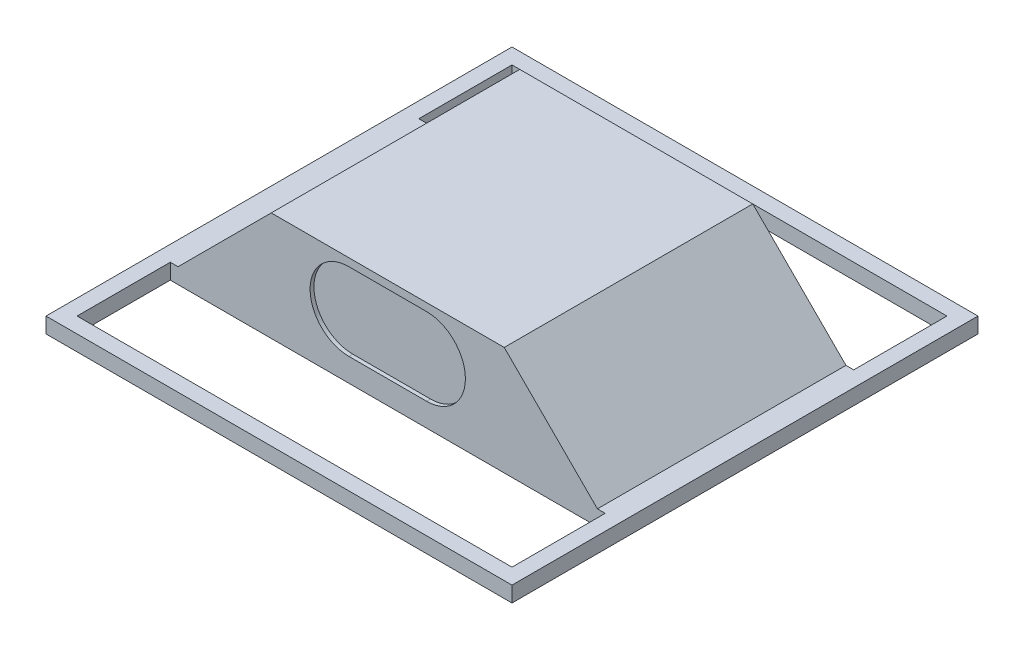
from build123d import *

# Parameters (mm, degrees)
SKETCH_1_W          = 600
SKETCH_1_H          = 600
SKETCH_1_W_2        = 560
SKETCH_1_H_2        = 120
EXTRUDE_1_DEPTH     = 20
EXTRUDE_2_DEPTH     = 320
CUT_EXTRUDE_1_DEPTH = 5
CUT_EXTRUDE_START   = -320
CUT_EXTRUDE_3_DEPTH = 5


with BuildPart() as part:
    # 草图1 → 凸台-拉伸1 (new body)
    with BuildSketch(Plane(origin=(0, 0, 0), x_dir=(1, 0, 0), z_dir=(0, 1, 0))):
        Rectangle(SKETCH_1_W, SKETCH_1_H)
        with Locations((0, 220)):
            Rectangle(SKETCH_1_W_2, SKETCH_1_H_2, mode=Mode.SUBTRACT)
        with Locations((0, -220)):
            Rectangle(SKETCH_1_W_2, SKETCH_1_H_2, mode=Mode.SUBTRACT)
    extrude(amount=EXTRUDE_1_DEPTH)

    # 草图2 → 凸台-拉伸2 (add)
    with BuildSketch(Plane.XY.offset(160)):
        Polygon((-270, 20), (-270, 0), (270, 0), (270, 20), (150, 140), (-150, 140), align=None)
    extrude(amount=-EXTRUDE_2_DEPTH)

    # 草图3 → 切除-拉伸1 (cut)
    with BuildSketch(Plane.XY.offset(160)):
        with BuildLine():
            Line((50, 130), (-50, 130))
            ThreePointArc((-50, 130), (-100, 80), (-50, 30))
            Line((-50, 30), (50, 30))
            ThreePointArc((50, 30), (100, 80), (50, 130))
        make_face()
    extrude(amount=-CUT_EXTRUDE_1_DEPTH, mode=Mode.SUBTRACT)

    # 草图3<3> → 切除-拉伸3 (cut)
    with BuildSketch(Plane.XY.offset(160).offset(CUT_EXTRUDE_START)):
        with BuildLine():
            Line((50, 130), (-50, 130))
            ThreePointArc((-50, 130), (-100, 80), (-50, 30))
            Line((-50, 30), (50, 30))
            ThreePointArc((50, 30), (100, 80), (50, 130))
        make_face()
    extrude(amount=CUT_EXTRUDE_3_DEPTH, mode=Mode.SUBTRACT)


solid = part.part
